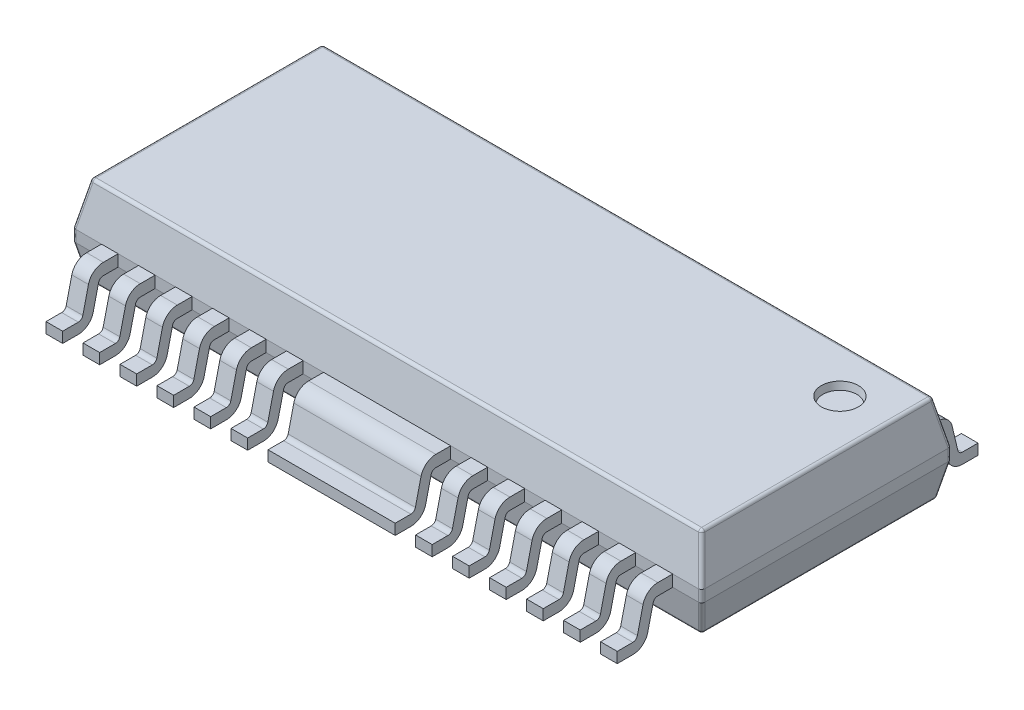
from build123d import *

# Parameters (mm, degrees)
SKETCH1_W                = 13.6
SKETCH1_H                = 5.4
EXTRUDE1_DEPTH           = 0.93
EXTRUDE1_TAPER           = 12
EXTRUDE1_OTHER_WAY_DEPTH = 0.25
SKETCH2_W                = 13.6
SKETCH2_H                = 5.4
EXTRUDE2_DEPTH           = 0.72
EXTRUDE2_TAPER           = 12
SKETCH3_R                = 0.4
CUT_EXTRUDE1_DEPTH       = 0.15
CUT_EXTRUDE1_TAPER       = 12
EXTRUDE3_DEPTH           = 0.18
LPATTERN3_COUNT          = 6
LPATTERN3_PITCH          = 0.8
EXTRUDE5_DEPTH           = 1.375
EXTRUDE5_DEPTH_BACK      = 1.375
EXTRUDE6_DEPTH           = 0.18
LPATTERN4_COUNT          = 6
LPATTERN4_PITCH          = 0.8
FILLET2_R                = 0.33
FILLET1_R                = 0.1
FILLET3_R                = 0.07


with BuildPart() as part:
    # Sketch1 → Extrude1 (new body)
    with BuildSketch(Plane(origin=(0, 0, 0), x_dir=(1, 0, 0), z_dir=(0, 1, 0))):
        Rectangle(SKETCH1_W, SKETCH1_H)
    extrude(amount=EXTRUDE1_DEPTH, taper=EXTRUDE1_TAPER)

    # Sketch1 → Extrude1 other way (add)
    with BuildSketch(Plane(origin=(0, 0, 0), x_dir=(1, 0, 0), z_dir=(0, 1, 0))):
        Rectangle(SKETCH1_W, SKETCH1_H)
    extrude(amount=-EXTRUDE1_OTHER_WAY_DEPTH)

    # Sketch2 → Extrude2 (add)
    with BuildSketch(Plane.XZ.offset(0.25)):
        Rectangle(SKETCH2_W, SKETCH2_H)
    extrude(amount=EXTRUDE2_DEPTH, taper=EXTRUDE2_TAPER)

    # Sketch3 → Cut-Extrude1 (cut)
    with BuildSketch(Plane(origin=(0, 0.93, 0), x_dir=(-1, 0, 0), z_dir=(0, 1, 0))):
        with Locations((-5.584055139, -1.505034096)):
            Circle(SKETCH3_R)
    extrude(amount=-CUT_EXTRUDE1_DEPTH, taper=CUT_EXTRUDE1_TAPER, mode=Mode.SUBTRACT)

    # Sketch4 → Extrude3 (add, symmetric)
    with BuildSketch(Plane(origin=(-1.995, 0, 0), x_dir=(0, 0, -1), z_dir=(1, 0, 0))):
        Polygon((2.7, -0.25), (-2.7, -0.25), (-3.104705882, -0.25), (-3.3, -1.08), (-3.9, -1.08), (-3.9, -0.85), (-3.482163371, -0.85), (-3.282163371, 0), (-2.7, 0), (2.7, 0), (3.282163371, 0), (3.482163371, -0.85), (3.9, -0.85), (3.9, -1.08), (3.3, -1.08), (3.104705882, -0.25), align=None)
    extrude3 = extrude(amount=EXTRUDE3_DEPTH, both=True)

    # LPattern3: Extrude3 ×6
    with Locations(*[(-i * LPATTERN3_PITCH, 0, 0) for i in range(1, LPATTERN3_COUNT)]):
        add(extrude3)

    # Sketch6 → Extrude5 (add, two sides)
    with BuildSketch(Plane(origin=(0, 0, 0), x_dir=(0, 0, -1), z_dir=(1, 0, 0))) as extrude5_sk:
        Polygon((3.9, -0.85), (3.482163371, -0.85), (3.282163371, 0), (2.7, 0), (-2.7, 0), (-3.282163371, 0), (-3.482163371, -0.85), (-3.9, -0.85), (-3.9, -1.08), (-3.3, -1.08), (-3.104705882, -0.25), (-2.7, -0.25), (2.7, -0.25), (3.104705882, -0.25), (3.3, -1.08), (3.9, -1.08), align=None)
    extrude(amount=EXTRUDE5_DEPTH)
    extrude(extrude5_sk.sketch, amount=-EXTRUDE5_DEPTH_BACK)

    # Sketch5 → Extrude6 (add, symmetric)
    with BuildSketch(Plane(origin=(1.995, 0, 0), x_dir=(0, 0, -1), z_dir=(1, 0, 0))):
        Polygon((3.9, -0.85), (3.482163371, -0.85), (3.282163371, 0), (2.7, 0), (-2.7, 0), (-3.282163371, 0), (-3.482163371, -0.85), (-3.9, -0.85), (-3.9, -1.08), (-3.3, -1.08), (-3.104705882, -0.25), (-2.7, -0.25), (2.7, -0.25), (3.104705882, -0.25), (3.3, -1.08), (3.9, -1.08), align=None)
    extrude6 = extrude(amount=EXTRUDE6_DEPTH, both=True)

    # LPattern4: Extrude6 ×6
    with Locations(*[(i * LPATTERN4_PITCH, 0, 0) for i in range(1, LPATTERN4_COUNT)]):
        add(extrude6)

    # Fillet2
    fillet2_edges = [part.edges().sort_by_distance(p)[0] for p in [
        (-2.795, -1.08, -3.3),
        (-2.795, 0, 3.282163371),
        (-2.795, -1.08, 3.3),
        (-3.595, 0, -3.282163371),
        (-3.595, -1.08, -3.3),
        (-3.595, 0, 3.282163371),
        (-3.595, -1.08, 3.3),
        (-4.395, 0, -3.282163371),
        (-4.395, -1.08, -3.3),
        (-4.395, 0, 3.282163371),
        (-4.395, -1.08, 3.3),
        (-5.195, 0, -3.282163371),
        (-5.195, -1.08, -3.3),
        (-5.195, 0, 3.282163371),
        (-5.195, -1.08, 3.3),
        (-5.995, 0, -3.282163371),
        (-5.995, -1.08, -3.3),
        (-5.995, 0, 3.282163371),
        (-5.995, -1.08, 3.3),
        (0, 0, -3.282163371),
        (0, 0, 3.282163371),
        (0, -1.08, 3.3),
        (0, -1.08, -3.3),
        (1.995, 0, -3.282163371),
        (1.995, 0, 3.282163371),
        (1.995, -1.08, 3.3),
        (1.995, -1.08, -3.3),
        (2.795, 0, -3.282163371),
        (2.795, 0, 3.282163371),
        (2.795, -1.08, 3.3),
        (2.795, -1.08, -3.3),
        (-1.995, 0, -3.282163371),
        (3.595, 0, -3.282163371),
        (3.595, 0, 3.282163371),
        (3.595, -1.08, 3.3),
        (3.595, -1.08, -3.3),
        (4.395, 0, -3.282163371),
        (4.395, 0, 3.282163371),
        (4.395, -1.08, 3.3),
        (4.395, -1.08, -3.3),
        (-1.995, -1.08, -3.3),
        (5.195, 0, -3.282163371),
        (-1.995, 0, 3.282163371),
        (5.195, 0, 3.282163371),
        (5.195, -1.08, 3.3),
        (5.195, -1.08, -3.3),
        (-1.995, -1.08, 3.3),
        (5.995, 0, -3.282163371),
        (5.995, 0, 3.282163371),
        (5.995, -1.08, 3.3),
        (5.995, -1.08, -3.3),
        (-2.795, 0, -3.282163371),
    ]]
    fillet(fillet2_edges, radius=FILLET2_R)

    # Fillet1
    fillet1_edges = [part.edges().sort_by_distance(p)[0] for p in [
        (-2.795, -0.25, -3.104705882),
        (-2.795, -0.85, -3.482163371),
        (-2.795, -0.85, 3.482163371),
        (-3.595, -0.25, 3.104705882),
        (-3.595, -0.25, -3.104705882),
        (-3.595, -0.85, -3.482163371),
        (-3.595, -0.85, 3.482163371),
        (-4.395, -0.25, 3.104705882),
        (-4.395, -0.25, -3.104705882),
        (-4.395, -0.85, -3.482163371),
        (-4.395, -0.85, 3.482163371),
        (-5.195, -0.25, 3.104705882),
        (-5.195, -0.25, -3.104705882),
        (-5.195, -0.85, -3.482163371),
        (-5.195, -0.85, 3.482163371),
        (-5.995, -0.25, 3.104705882),
        (-5.995, -0.25, -3.104705882),
        (-5.995, -0.85, -3.482163371),
        (-5.995, -0.85, 3.482163371),
        (0, -0.25, 3.104705882),
        (0, -0.85, -3.482163371),
        (0, -0.85, 3.482163371),
        (0, -0.25, -3.104705882),
        (1.995, -0.25, 3.104705882),
        (1.995, -0.85, -3.482163371),
        (1.995, -0.85, 3.482163371),
        (1.995, -0.25, -3.104705882),
        (2.795, -0.25, 3.104705882),
        (2.795, -0.85, -3.482163371),
        (2.795, -0.85, 3.482163371),
        (2.795, -0.25, -3.104705882),
        (3.595, -0.25, 3.104705882),
        (3.595, -0.85, -3.482163371),
        (3.595, -0.85, 3.482163371),
        (-1.995, -0.25, 3.104705882),
        (3.595, -0.25, -3.104705882),
        (4.395, -0.25, 3.104705882),
        (4.395, -0.85, -3.482163371),
        (4.395, -0.85, 3.482163371),
        (4.395, -0.25, -3.104705882),
        (-1.995, -0.25, -3.104705882),
        (-1.995, -0.85, -3.482163371),
        (5.195, -0.25, 3.104705882),
        (5.195, -0.85, -3.482163371),
        (5.195, -0.85, 3.482163371),
        (-1.995, -0.85, 3.482163371),
        (5.195, -0.25, -3.104705882),
        (5.995, -0.25, 3.104705882),
        (5.995, -0.85, -3.482163371),
        (5.995, -0.85, 3.482163371),
        (5.995, -0.25, -3.104705882),
        (-2.795, -0.25, 3.104705882),
    ]]
    fillet(fillet1_edges, radius=FILLET1_R)

    # Fillet3
    fillet3_edges = [part.edges().sort_by_distance(p)[0] for p in [
        (6.602322398, 0.93, 0),
        (-6.8, -0.125, 2.7),
        (0, 0.93, -2.502322398),
        (-6.8, -0.125, -2.7),
        (6.8, -0.125, -2.7),
        (6.8, -0.125, 2.7),
        (6.723479638, -0.61, 2.623479638),
        (-6.723479638, -0.61, 2.623479638),
        (-6.723479638, -0.61, -2.623479638),
        (6.723479638, -0.61, -2.623479638),
        (0, -0.97, 2.546959276),
        (-6.646959276, -0.97, 0),
        (0, -0.97, -2.546959276),
        (6.646959276, -0.97, 0),
        (-6.602322398, 0.93, 0),
        (0, 0.93, 2.502322398),
        (-6.701161199, 0.465, -2.601161199),
        (6.701161199, 0.465, -2.601161199),
        (6.701161199, 0.465, 2.601161199),
        (-6.701161199, 0.465, 2.601161199),
    ]]
    fillet(fillet3_edges, radius=FILLET3_R)


solid = part.part
